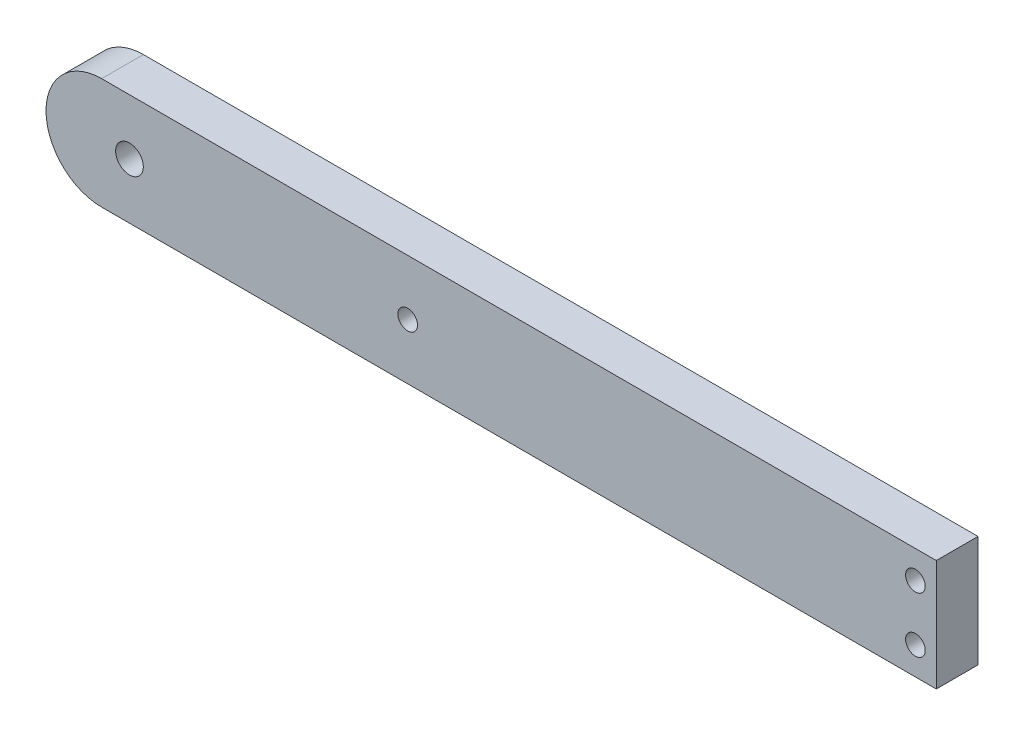
from build123d import *

# Parameters (mm, degrees)
SKETCH1_W                 = 203.2
SKETCH1_H                 = 25.4
BOSS_EXTRUDE1_DEPTH       = 9.525
F_8_CLEARANCE_HOLE1_D     = 4.4958
F_8_CLEARANCE_HOLE1_DEPTH = 25.4
F_8_CLEARANCE_HOLE1_TIP   = 1.350674586
SKETCH5_R                 = 3.1623
CUT_EXTRUDE1_DEPTH        = 9.525
F_8_CLEARANCE_HOLE2_D     = 4.4958
F_8_CLEARANCE_HOLE2_DEPTH = 19.05
F_8_CLEARANCE_HOLE2_TIP   = 1.350674586
CUT_EXTRUDE2_DEPTH        = 10.525


with BuildPart() as part:
    # Sketch1 → Boss-Extrude1 (new body)
    with BuildSketch(Plane.XY):
        with Locations((-101.6, 12.7)):
            Rectangle(SKETCH1_W, SKETCH1_H)
    extrude(amount=BOSS_EXTRUDE1_DEPTH)

    # #8 Clearance Hole1
    with Locations(Plane.XY.offset(9.525)):
        with Locations((-4.7625, 6.35), (-4.7625, 19.05)):
            Hole(F_8_CLEARANCE_HOLE1_D / 2, depth=F_8_CLEARANCE_HOLE1_DEPTH)
            with Locations((0, 0, -(F_8_CLEARANCE_HOLE1_DEPTH + F_8_CLEARANCE_HOLE1_TIP / 2))):  # 118° drill point
                Cone(0, F_8_CLEARANCE_HOLE1_D / 2, F_8_CLEARANCE_HOLE1_TIP, mode=Mode.SUBTRACT)

    # Sketch5 → Cut-Extrude1 (cut)
    with BuildSketch(Plane.XY.offset(9.525)):
        with Locations((-184.15, 12.7)):
            Circle(SKETCH5_R)
    extrude(amount=-CUT_EXTRUDE1_DEPTH, mode=Mode.SUBTRACT)

    # #8 Clearance Hole2
    with Locations(Plane.XY.offset(9.525)):
        with Locations((-120.65, 12.7)):
            Hole(F_8_CLEARANCE_HOLE2_D / 2, depth=F_8_CLEARANCE_HOLE2_DEPTH)
            with Locations((0, 0, -(F_8_CLEARANCE_HOLE2_DEPTH + F_8_CLEARANCE_HOLE2_TIP / 2))):  # 118° drill point
                Cone(0, F_8_CLEARANCE_HOLE2_D / 2, F_8_CLEARANCE_HOLE2_TIP, mode=Mode.SUBTRACT)

    # Sketch10 → Cut-Extrude2 (cut, through all)
    with BuildSketch(Plane.XY.offset(9.525)):
        with BuildLine():
            Line((-190.5, 25.4), (-203.2, 25.4))
            Line((-203.2, 25.4), (-203.2, 12.7))
            ThreePointArc((-203.2, 12.7), (-199.480256121, 21.680256121), (-190.5, 25.4))
        make_face()
        with BuildLine():
            ThreePointArc((-190.5, 0), (-199.480256121, 3.719743879), (-203.2, 12.7))
            Line((-203.2, 12.7), (-203.2, 0))
            Line((-203.2, 0), (-190.5, 0))
        make_face()
    extrude(amount=-CUT_EXTRUDE2_DEPTH, mode=Mode.SUBTRACT)


solid = part.part
